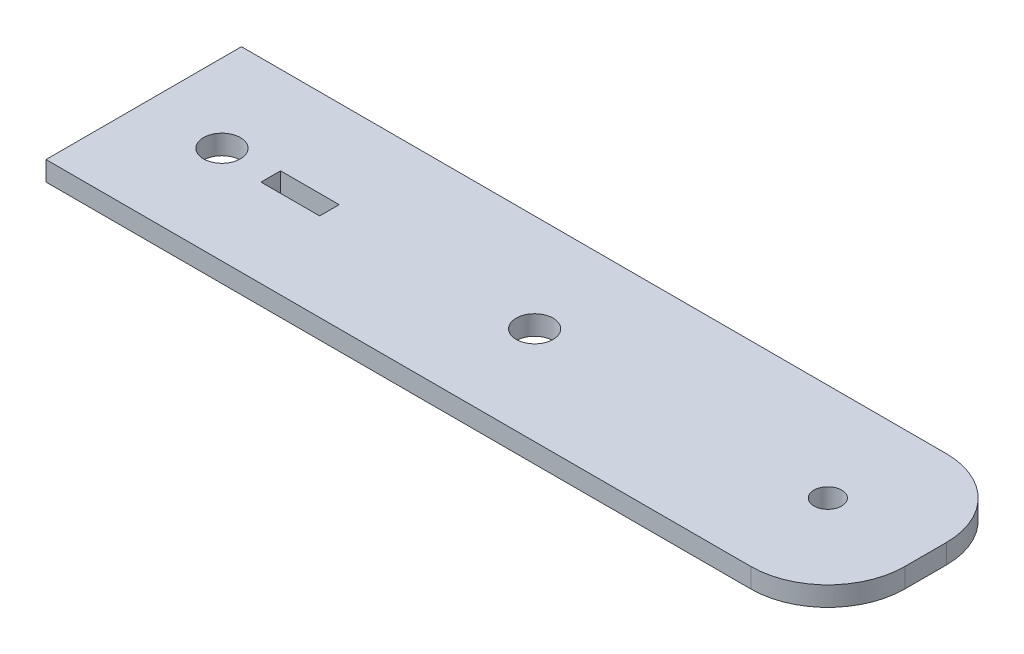
from build123d import *

# Parameters (mm, degrees)
SKETCH1_R           = 3
SKETCH1_R_2         = 2.25
SKETCH1_W           = 9.525
SKETCH1_H           = 3.175
BOSS_EXTRUDE1_DEPTH = 3.175


with BuildPart() as part:
    # Sketch1 → Boss-Extrude1 (new body)
    with BuildSketch(Plane(origin=(0, 0, 0), x_dir=(1, 0, 0), z_dir=(0, 1, 0))):
        with BuildLine():
            Line((-12.7, -15.875), (101.8, -15.875))
            ThreePointArc((101.8, -15.875), (110.638834765, -12.213834765), (114.3, -3.375))
            Line((114.3, -3.375), (114.3, 3.375))
            ThreePointArc((114.3, 3.375), (110.638834765, 12.213834765), (101.8, 15.875))
            Line((101.8, 15.875), (-12.7, 15.875))
            Line((-12.7, 15.875), (-12.7, -15.875))
        make_face()
        Circle(SKETCH1_R, mode=Mode.SUBTRACT)
        with Locations((98.425, 0)):
            Circle(SKETCH1_R_2, mode=Mode.SUBTRACT)
        with Locations((50.8, 0)):
            Circle(SKETCH1_R, mode=Mode.SUBTRACT)
        with Locations((12.7, 0)):
            Rectangle(SKETCH1_W, SKETCH1_H, mode=Mode.SUBTRACT)
    extrude(amount=BOSS_EXTRUDE1_DEPTH)


solid = part.part
